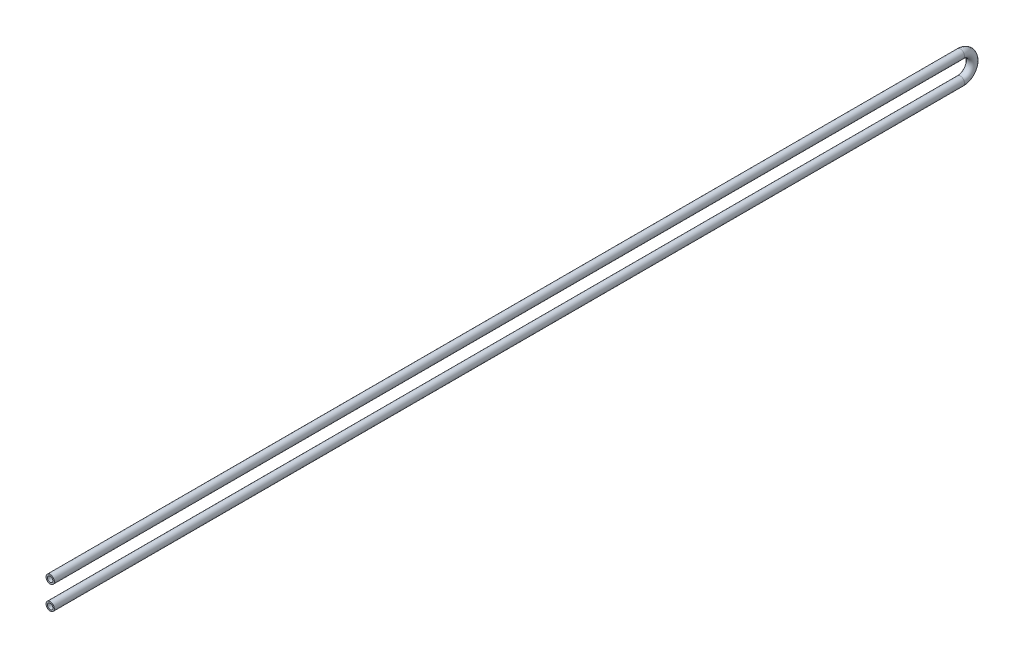
from build123d import *

# Parameters (mm, degrees)
SKETCH2_R   = 10.65
SKETCH2_R_2 = 6.92


with BuildPart() as part:
    # Sweep1: sweep along a path in Sketch1
    with BuildLine(Plane(origin=(0, 0, 0), x_dir=(0, 0, -1), z_dir=(1, 0, 0))) as sweep1_path:
        Line((0, 30), (2325, 30))
        ThreePointArc((2325, 30), (2355, 0), (2325, -30))
        Line((2325, -30), (0, -30))
    # Sketch2 → Sweep1 (sweep)
    with BuildSketch(Plane.XY):
        with Locations((0, 30)):
            Circle(SKETCH2_R)
        with Locations((0, 30)):
            Circle(SKETCH2_R_2, mode=Mode.SUBTRACT)
    sweep(path=sweep1_path.line)


solid = part.part
